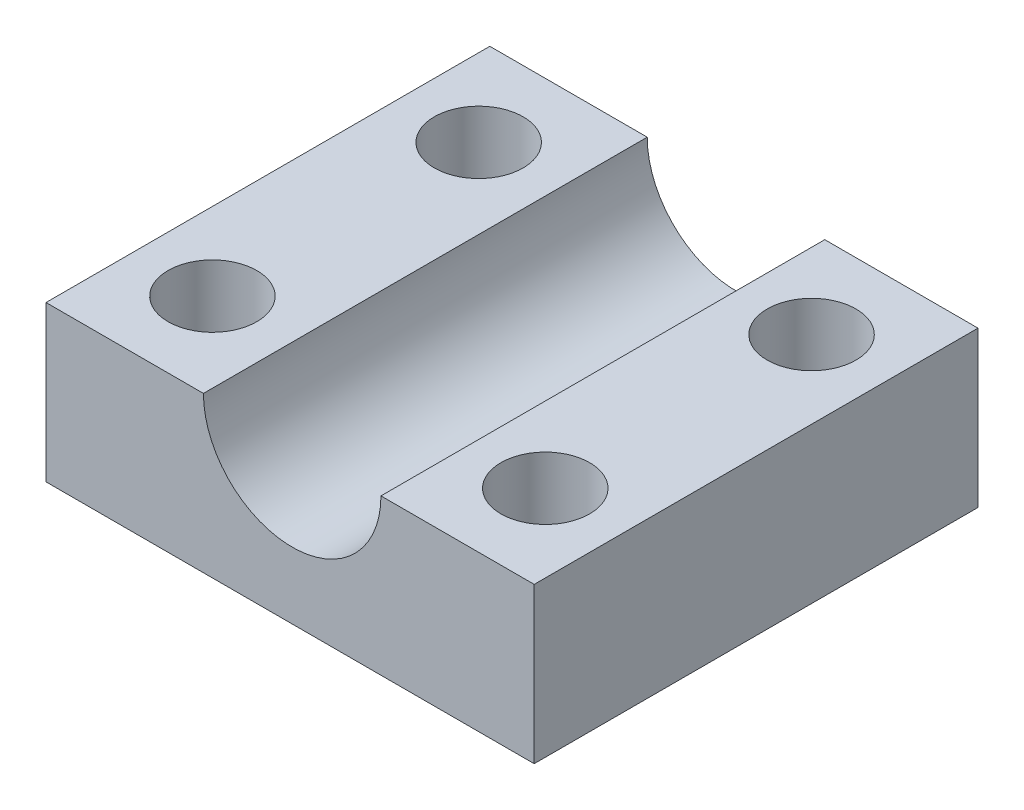
from build123d import *

# Parameters (mm, degrees)
SKETCH1_W                      = 44
SKETCH1_H                      = 40
SKETCH1_R                      = 4
BOSS_EXTRUDE1_DEPTH            = 14
CUT_EXTRUDE1_REACH             = 18.442
SKETCH2_R                      = 8
CUT_EXTRUDE1_DIRECTION_2_REACH = 25.558


with BuildPart() as part:
    # Sketch1 → Boss-Extrude1 (new body)
    with BuildSketch(Plane(origin=(0, 0, 0), x_dir=(1, 0, 0), z_dir=(0, 1, 0))):
        with Locations((-0.188936111, 3.557633072)):
            Rectangle(SKETCH1_W, SKETCH1_H)
        with Locations((14.811063889, -8.442366928)):
            Circle(SKETCH1_R, mode=Mode.SUBTRACT)
        with Locations((14.811063889, 15.557633072)):
            Circle(SKETCH1_R, mode=Mode.SUBTRACT)
        with Locations((-15.188936111, 15.557633072)):
            Circle(SKETCH1_R, mode=Mode.SUBTRACT)
        with Locations((-15.188936111, -8.442366928)):
            Circle(SKETCH1_R, mode=Mode.SUBTRACT)
    extrude(amount=BOSS_EXTRUDE1_DEPTH)

    # Cut-Extrude1: up to this face of the body (flat: up to its plane)
    cut_extrude1_end = Plane(part.part.faces().sort_by_distance((-0.188936111, 7, 16.442366928))[0])
    # Sketch2 → Cut-Extrude1 (cut, up to the picked face)
    with BuildSketch(Plane.XY, mode=Mode.PRIVATE) as cut_extrude1_sk1:
        with Locations((0, 14)):
            Circle(SKETCH2_R)
    cut_extrude1_tool1 = split(extrude(cut_extrude1_sk1.sketch, amount=CUT_EXTRUDE1_REACH, mode=Mode.PRIVATE), bisect_by=cut_extrude1_end, keep=Keep.BOTH, mode=Mode.PRIVATE)
    add(cut_extrude1_tool1.solids().sort_by_distance((0, 14, 0))[0], mode=Mode.SUBTRACT)

    # Cut-Extrude1 direction 2: up to this face of the body (flat: up to its plane)
    cut_extrude1_direction_2_end = Plane(part.part.faces().sort_by_distance((-0.188936111, 7, -23.557633072))[0])
    # Sketch2 → Cut-Extrude1 direction 2 (cut, up to the picked face)
    with BuildSketch(Plane.XY, mode=Mode.PRIVATE) as cut_extrude1_direction_2_sk1:
        with Locations((0, 14)):
            Circle(SKETCH2_R)
    cut_extrude1_direction_2_tool1 = split(extrude(cut_extrude1_direction_2_sk1.sketch, amount=-CUT_EXTRUDE1_DIRECTION_2_REACH, mode=Mode.PRIVATE), bisect_by=cut_extrude1_direction_2_end, keep=Keep.BOTH, mode=Mode.PRIVATE)
    add(cut_extrude1_direction_2_tool1.solids().sort_by_distance((0, 14, 0))[0], mode=Mode.SUBTRACT)


solid = part.part
